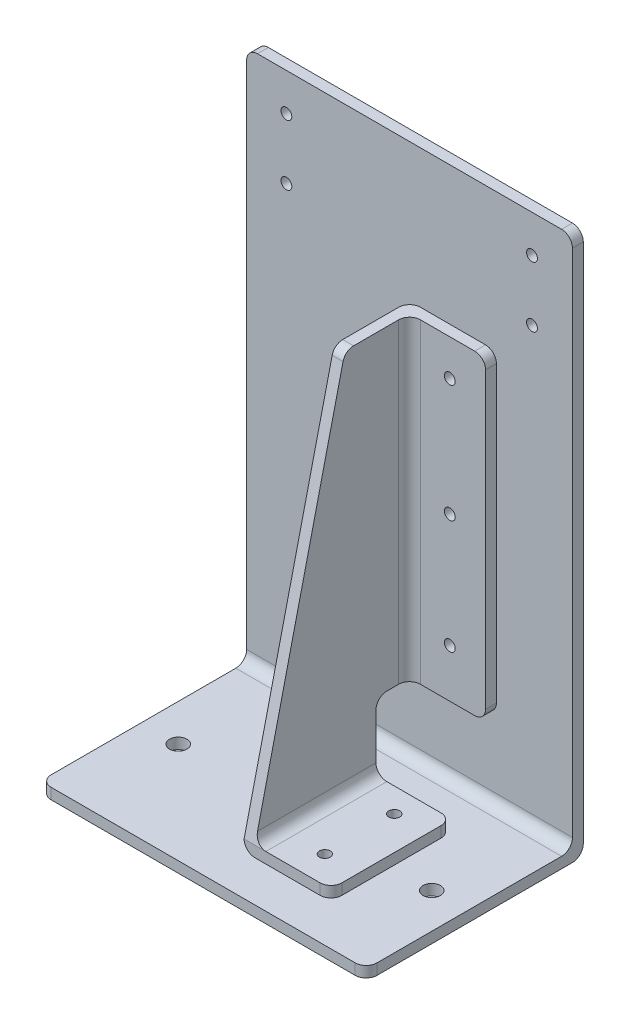
from build123d import *

# Parameters (mm, degrees)
BOSS_EXTRUDE1_DEPTH             = 300
BOSS_EXTRUDE2_START             = -140
BOSS_EXTRUDE2_DEPTH             = 10
BOSS_EXTRUDE3_START             = -150
SKETCH2_3_W                     = 111.42684815
SKETCH2_3_H                     = 10
SKETCH2_3_W_2                   = 10
SKETCH2_3_H_2                   = 290.655213081
BOSS_EXTRUDE3_DEPTH             = 80
FILLET1_R                       = 10
FILLET2_R                       = 10
SKETCH4_W                       = 5
SKETCH4_H                       = 20
F_10_0MM_DOWEL_HOLE1_AT_2_COUNT = 2
F_10_0MM_DOWEL_HOLE1_AT_2_PITCH = 108.110572907
F_10_0MM_DOWEL_HOLE1_AT_3_COUNT = 2
F_10_0MM_DOWEL_HOLE1_AT_3_PITCH = 212.904870572
F_10_0MM_DOWEL_HOLE1_AT_4_COUNT = 2
F_10_0MM_DOWEL_HOLE1_AT_4_PITCH = 142.099201661
F_10_0MM_DOWEL_HOLE1_AT_5_COUNT = 2
F_10_0MM_DOWEL_HOLE1_AT_5_PITCH = 96.199423156
F_10_0MM_DOWEL_HOLE1_AT_6_COUNT = 2
F_10_0MM_DOWEL_HOLE1_AT_6_PITCH = 175.229925254
F_10_0MM_DOWEL_HOLE1_AT_7_COUNT = 2
F_10_0MM_DOWEL_HOLE1_AT_7_PITCH = 204.067098773
SKETCH7_W                       = 5
SKETCH7_H                       = 20
F_10_0MM_DOWEL_HOLE2_AT_2_COUNT = 2
F_10_0MM_DOWEL_HOLE2_AT_2_PITCH = 63.961905042
SKETCH9_W                       = 8
SKETCH9_H                       = 10
F_16_0MM_DOWEL_HOLE1_AT_2_COUNT = 2
F_16_0MM_DOWEL_HOLE1_AT_2_PITCH = 233.399451571


with BuildPart() as part:
    # Sketch1 → Boss-Extrude1 (new body)
    with BuildSketch(Plane(origin=(0, 0, 0), x_dir=(0, 0, -1), z_dir=(1, 0, 0))):
        Polygon((0, 0), (0, 500), (-10, 500), (-10, 10), (-200, 10), (-200, 0), align=None)
    extrude(amount=-BOSS_EXTRUDE1_DEPTH)

    # Fillet1
    fillet1_edges = [part.edges().sort_by_distance(p)[0] for p in [
        (-300, 500, 5),
        (-150, 0, 0),
        (-150, 10, 10),
        (-300, 5, 200),
        (0, 5, 200),
        (0, 500, 5),
    ]]
    fillet(fillet1_edges, radius=FILLET1_R)


with BuildPart() as body_2:
    # Sketch2 → Boss-Extrude2 (new body)
    with BuildSketch(Plane(origin=(0, 0, 0), x_dir=(0, 0, -1), z_dir=(1, 0, 0)).offset(BOSS_EXTRUDE2_START)):
        Polygon((-20, 82.196472727), (-20, 372.851685808), (-79.439093496, 372.851685808), (-162.34597456, 20), (-50.91912641, 20), (-50.91912641, 82.196472727), align=None)
    extrude(amount=-BOSS_EXTRUDE2_DEPTH)

    # Sketch2_3 → Boss-Extrude3 (add)
    with BuildSketch(Plane(origin=(0, 0, 0), x_dir=(0, 0, -1), z_dir=(1, 0, 0)).offset(BOSS_EXTRUDE3_START)):
        with Locations((-106.632550485, 15)):
            Rectangle(SKETCH2_3_W, SKETCH2_3_H)
        with Locations((-15, 227.524079268)):
            Rectangle(SKETCH2_3_W_2, SKETCH2_3_H_2)
    extrude(amount=BOSS_EXTRUDE3_DEPTH)

    # Fillet2
    fillet2_edges = [body_2.edges().sort_by_distance(p)[0] for p in [
        (-145, 82.196472727, 50.91912641),
        (-150, 10, 106.632550485),
        (-70, 15, 50.91912641),
        (-70, 15, 162.34597456),
        (-70, 82.196472727, 15),
        (-140, 227.524079267, 20),
        (-145, 372.851685808, 79.439093496),
        (-70, 372.851685808, 15),
        (-150, 227.524079267, 10),
        (-140, 20, 106.632550485),
    ]]
    fillet(fillet2_edges, radius=FILLET2_R)


with BuildPart() as f_10_0mm_dowel_hole1_tool:
    # Sketch4 → Ø10.0mm Dowel Hole1 (revolve)
    with BuildSketch(Plane(origin=(-102.908891556, 339.539431549, 20), x_dir=(0, -1, 0), z_dir=(1, 0, 0))):
        with Locations((2.5, 10)):
            Rectangle(SKETCH4_W, SKETCH4_H)
    f_10_0mm_dowel_hole1 = revolve(axis=Axis((-102.908891556, 339.539431549, 26.35), (0, 0, -1)))


with BuildPart() as part_1:
    add(part.part)

    # Ø10.0mm Dowel Hole1: cut by f_10_0mm_dowel_hole1_tool
    add(f_10_0mm_dowel_hole1_tool.part, mode=Mode.SUBTRACT)


with BuildPart() as body_2_1:
    add(body_2.part)

    # Ø10.0mm Dowel Hole1: cut by f_10_0mm_dowel_hole1_tool
    add(f_10_0mm_dowel_hole1_tool.part, mode=Mode.SUBTRACT)


with BuildPart() as f_10_0mm_dowel_hole1_at_2_tool:
    # Ø10.0mm Dowel Hole1 at 2: Ø10.0mm Dowel Hole1 ×2
    with Locations(*[(0, -i * F_10_0MM_DOWEL_HOLE1_AT_2_PITCH, 0) for i in range(1, F_10_0MM_DOWEL_HOLE1_AT_2_COUNT)]):
        add(f_10_0mm_dowel_hole1)


with BuildPart() as part_2:
    add(part_1.part)

    # Ø10.0mm Dowel Hole1 at 2: cut by f_10_0mm_dowel_hole1_at_2_tool
    add(f_10_0mm_dowel_hole1_at_2_tool.part, mode=Mode.SUBTRACT)


with BuildPart() as body_2_2:
    add(body_2_1.part)

    # Ø10.0mm Dowel Hole1 at 2: cut by f_10_0mm_dowel_hole1_at_2_tool
    add(f_10_0mm_dowel_hole1_at_2_tool.part, mode=Mode.SUBTRACT)


with BuildPart() as f_10_0mm_dowel_hole1_at_3_tool:
    # Ø10.0mm Dowel Hole1 at 3: Ø10.0mm Dowel Hole1 ×2
    with Locations(*[(0, -i * F_10_0MM_DOWEL_HOLE1_AT_3_PITCH, 0) for i in range(1, F_10_0MM_DOWEL_HOLE1_AT_3_COUNT)]):
        add(f_10_0mm_dowel_hole1)


with BuildPart() as part_3:
    add(part_2.part)

    # Ø10.0mm Dowel Hole1 at 3: cut by f_10_0mm_dowel_hole1_at_3_tool
    add(f_10_0mm_dowel_hole1_at_3_tool.part, mode=Mode.SUBTRACT)

    # Ø10.0mm Dowel Hole1 at 4: Ø10.0mm Dowel Hole1 ×2
    with Locations(*[Vector(0.462087394, 0.886834393, 0) * (i * F_10_0MM_DOWEL_HOLE1_AT_4_PITCH) for i in range(1, F_10_0MM_DOWEL_HOLE1_AT_4_COUNT)]):
        add(f_10_0mm_dowel_hole1, mode=Mode.SUBTRACT)

    # Ø10.0mm Dowel Hole1 at 5: Ø10.0mm Dowel Hole1 ×2
    with Locations(*[Vector(0.682563862, 0.730825953, 0) * (i * F_10_0MM_DOWEL_HOLE1_AT_5_PITCH) for i in range(1, F_10_0MM_DOWEL_HOLE1_AT_5_COUNT)]):
        add(f_10_0mm_dowel_hole1, mode=Mode.SUBTRACT)

    # Ø10.0mm Dowel Hole1 at 6: Ø10.0mm Dowel Hole1 ×2
    with Locations(*[Vector(-0.915983509, 0.401215917, 0) * (i * F_10_0MM_DOWEL_HOLE1_AT_6_PITCH) for i in range(1, F_10_0MM_DOWEL_HOLE1_AT_6_COUNT)]):
        add(f_10_0mm_dowel_hole1, mode=Mode.SUBTRACT)

    # Ø10.0mm Dowel Hole1 at 7: Ø10.0mm Dowel Hole1 ×2
    with Locations(*[Vector(-0.786543851, 0.617534429, 0) * (i * F_10_0MM_DOWEL_HOLE1_AT_7_PITCH) for i in range(1, F_10_0MM_DOWEL_HOLE1_AT_7_COUNT)]):
        add(f_10_0mm_dowel_hole1, mode=Mode.SUBTRACT)


with BuildPart() as body_2_3:
    add(body_2_2.part)

    # Ø10.0mm Dowel Hole1 at 3: cut by f_10_0mm_dowel_hole1_at_3_tool
    add(f_10_0mm_dowel_hole1_at_3_tool.part, mode=Mode.SUBTRACT)


with BuildPart() as f_10_0mm_dowel_hole2_tool:
    # Sketch7 → Ø10.0mm Dowel Hole2 (revolve)
    with BuildSketch(Plane(origin=(-100.798534583, 20, 73.24670318), x_dir=(0, 0, 1), z_dir=(1, 0, 0))):
        with Locations((2.5, 10)):
            Rectangle(SKETCH7_W, SKETCH7_H)
    f_10_0mm_dowel_hole2 = revolve(axis=Axis((-100.798534583, 26.35, 73.24670318), (0, -1, 0)))


with BuildPart() as part_4:
    add(part_3.part)

    # Ø10.0mm Dowel Hole2: cut by f_10_0mm_dowel_hole2_tool
    add(f_10_0mm_dowel_hole2_tool.part, mode=Mode.SUBTRACT)


with BuildPart() as body_2_4:
    add(body_2_3.part)

    # Ø10.0mm Dowel Hole2: cut by f_10_0mm_dowel_hole2_tool
    add(f_10_0mm_dowel_hole2_tool.part, mode=Mode.SUBTRACT)


with BuildPart() as f_10_0mm_dowel_hole2_at_2_tool:
    # Ø10.0mm Dowel Hole2 at 2: Ø10.0mm Dowel Hole2 ×2
    with Locations(*[(0, 0, i * F_10_0MM_DOWEL_HOLE2_AT_2_PITCH) for i in range(1, F_10_0MM_DOWEL_HOLE2_AT_2_COUNT)]):
        add(f_10_0mm_dowel_hole2)


with BuildPart() as part_5:
    add(part_4.part)

    # Ø10.0mm Dowel Hole2 at 2: cut by f_10_0mm_dowel_hole2_at_2_tool
    add(f_10_0mm_dowel_hole2_at_2_tool.part, mode=Mode.SUBTRACT)

    # Sketch9 → Ø16.0mm Dowel Hole1 (revolve, cut)
    with BuildSketch(Plane(origin=(-32.531501317, 10, 107.072710654), x_dir=(0, 0, 1), z_dir=(1, 0, 0))):
        with Locations((4, 5)):
            Rectangle(SKETCH9_W, SKETCH9_H)
    f_16_0mm_dowel_hole1 = revolve(axis=Axis((-32.531501317, 16.35, 107.072710654), (0, -1, 0)), mode=Mode.SUBTRACT)

    # Ø16.0mm Dowel Hole1 at 2: Ø16.0mm Dowel Hole1 ×2
    with Locations(*[(-i * F_16_0MM_DOWEL_HOLE1_AT_2_PITCH, 0, 0) for i in range(1, F_16_0MM_DOWEL_HOLE1_AT_2_COUNT)]):
        add(f_16_0mm_dowel_hole1, mode=Mode.SUBTRACT)


with BuildPart() as body_2_5:
    add(body_2_4.part)

    # Ø10.0mm Dowel Hole2 at 2: cut by f_10_0mm_dowel_hole2_at_2_tool
    add(f_10_0mm_dowel_hole2_at_2_tool.part, mode=Mode.SUBTRACT)


solid = Compound([part_5.part, body_2_5.part])
